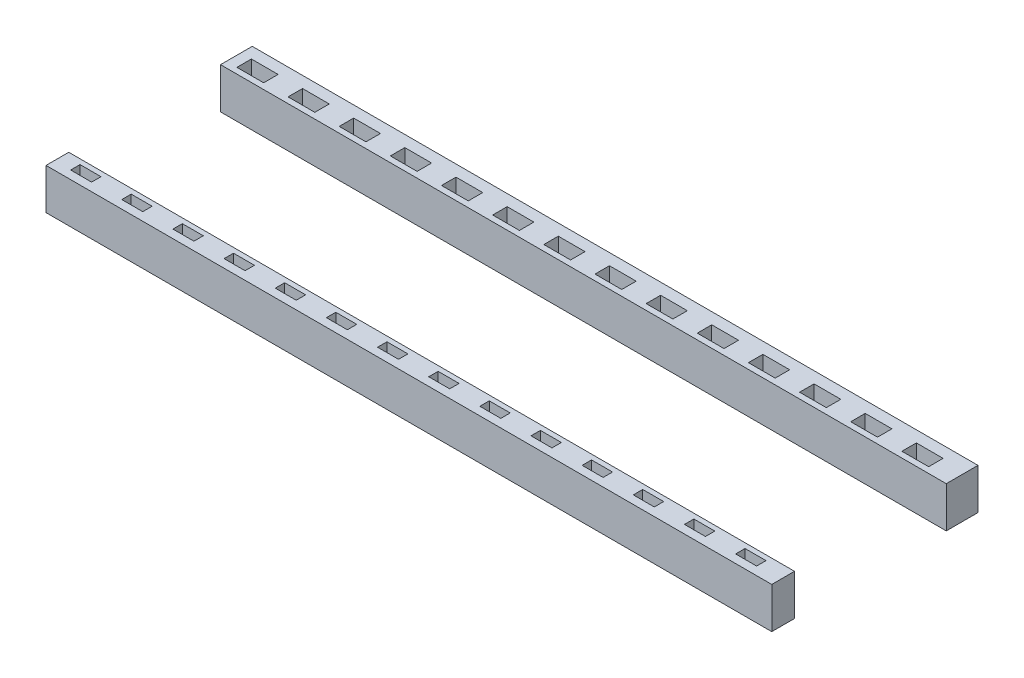
from build123d import *

# Parameters (mm, degrees)
CROQUIS1_W                = 35.470504615
CROQUIS1_H                = 1.551006647
CROQUIS1_W_2              = 1.307281122
CROQUIS1_H_2              = 0.706638445
SALIENTE_EXTRUIR1_DEPTH   = 2
CROQUIS1_H_3              = 1.112257887
CROQUIS1_W_3              = 1.024625744
CROQUIS1_H_4              = 0.459314989
SALIENTE_EXTRUIR1_2_DEPTH = 2
CROQUIS1_3_W              = 1.307281122
CROQUIS1_3_H              = 0.706638445
CROQUIS1_3_W_2            = 1.024625744
CROQUIS1_3_H_2            = 0.459314989
SALIENTE_EXTRUIR2_DEPTH   = 1


with BuildPart() as part:
    # Croquis1 → Saliente-Extruir1 (new body)
    with BuildSketch(Plane(origin=(0, 32.468175746, 0), x_dir=(1, 0, 0), z_dir=(0, 1, 0))):
        with Locations((31.911205321, -56.71845489)):
            Rectangle(CROQUIS1_W, CROQUIS1_H)
        with Locations((15.344131363, -56.853250782)):
            Rectangle(CROQUIS1_W_2, CROQUIS1_H_2, mode=Mode.SUBTRACT)
        with Locations((17.844131363, -56.853250782)):
            Rectangle(CROQUIS1_W_2, CROQUIS1_H_2, mode=Mode.SUBTRACT)
        with Locations((20.344131363, -56.853250782)):
            Rectangle(CROQUIS1_W_2, CROQUIS1_H_2, mode=Mode.SUBTRACT)
        with Locations((22.844131363, -56.853250782)):
            Rectangle(CROQUIS1_W_2, CROQUIS1_H_2, mode=Mode.SUBTRACT)
        with Locations((25.344131363, -56.853250782)):
            Rectangle(CROQUIS1_W_2, CROQUIS1_H_2, mode=Mode.SUBTRACT)
        with Locations((27.844131363, -56.853250782)):
            Rectangle(CROQUIS1_W_2, CROQUIS1_H_2, mode=Mode.SUBTRACT)
        with Locations((30.344131363, -56.853250782)):
            Rectangle(CROQUIS1_W_2, CROQUIS1_H_2, mode=Mode.SUBTRACT)
        with Locations((32.844131363, -56.853250782)):
            Rectangle(CROQUIS1_W_2, CROQUIS1_H_2, mode=Mode.SUBTRACT)
        with Locations((35.344131363, -56.853250782)):
            Rectangle(CROQUIS1_W_2, CROQUIS1_H_2, mode=Mode.SUBTRACT)
        with Locations((37.844131363, -56.853250782)):
            Rectangle(CROQUIS1_W_2, CROQUIS1_H_2, mode=Mode.SUBTRACT)
        with Locations((40.344131363, -56.853250782)):
            Rectangle(CROQUIS1_W_2, CROQUIS1_H_2, mode=Mode.SUBTRACT)
        with Locations((42.844131363, -56.853250782)):
            Rectangle(CROQUIS1_W_2, CROQUIS1_H_2, mode=Mode.SUBTRACT)
        with Locations((45.344131363, -56.853250782)):
            Rectangle(CROQUIS1_W_2, CROQUIS1_H_2, mode=Mode.SUBTRACT)
        with Locations((47.844131363, -56.853250782)):
            Rectangle(CROQUIS1_W_2, CROQUIS1_H_2, mode=Mode.SUBTRACT)
    extrude(amount=SALIENTE_EXTRUIR1_DEPTH)



with BuildPart() as body_2:
    # Croquis1 → Saliente-Extruir1 2 (new body)
    with BuildSketch(Plane(origin=(0, 32.468175746, 0), x_dir=(1, 0, 0), z_dir=(0, 1, 0))):
        with Locations((31.911205321, -65.466420603)):
            Rectangle(CROQUIS1_W, CROQUIS1_H_3)
        with Locations((15.485459052, -65.385910001)):
            Rectangle(CROQUIS1_W_3, CROQUIS1_H_4, mode=Mode.SUBTRACT)
        with Locations((17.985459052, -65.385910001)):
            Rectangle(CROQUIS1_W_3, CROQUIS1_H_4, mode=Mode.SUBTRACT)
        with Locations((20.485459052, -65.385910001)):
            Rectangle(CROQUIS1_W_3, CROQUIS1_H_4, mode=Mode.SUBTRACT)
        with Locations((22.985459052, -65.385910001)):
            Rectangle(CROQUIS1_W_3, CROQUIS1_H_4, mode=Mode.SUBTRACT)
        with Locations((25.485459052, -65.385910001)):
            Rectangle(CROQUIS1_W_3, CROQUIS1_H_4, mode=Mode.SUBTRACT)
        with Locations((27.985459052, -65.385910001)):
            Rectangle(CROQUIS1_W_3, CROQUIS1_H_4, mode=Mode.SUBTRACT)
        with Locations((30.485459052, -65.385910001)):
            Rectangle(CROQUIS1_W_3, CROQUIS1_H_4, mode=Mode.SUBTRACT)
        with Locations((32.985459052, -65.385910001)):
            Rectangle(CROQUIS1_W_3, CROQUIS1_H_4, mode=Mode.SUBTRACT)
        with Locations((35.485459052, -65.385910001)):
            Rectangle(CROQUIS1_W_3, CROQUIS1_H_4, mode=Mode.SUBTRACT)
        with Locations((37.985459052, -65.385910001)):
            Rectangle(CROQUIS1_W_3, CROQUIS1_H_4, mode=Mode.SUBTRACT)
        with Locations((40.485459052, -65.385910001)):
            Rectangle(CROQUIS1_W_3, CROQUIS1_H_4, mode=Mode.SUBTRACT)
        with Locations((42.985459052, -65.385910001)):
            Rectangle(CROQUIS1_W_3, CROQUIS1_H_4, mode=Mode.SUBTRACT)
        with Locations((45.485459052, -65.385910001)):
            Rectangle(CROQUIS1_W_3, CROQUIS1_H_4, mode=Mode.SUBTRACT)
        with Locations((47.985459052, -65.385910001)):
            Rectangle(CROQUIS1_W_3, CROQUIS1_H_4, mode=Mode.SUBTRACT)
    extrude(amount=SALIENTE_EXTRUIR1_2_DEPTH)


with BuildPart() as part_1:
    add(part.part)

    add(body_2.part)  # Saliente-Extruir2 merges body 2
    # Croquis1_3 → Saliente-Extruir2 (add)
    with BuildSketch(Plane(origin=(0, 32.468175746, 0), x_dir=(1, 0, 0), z_dir=(0, 1, 0))):
        with Locations((17.844131363, -56.853250782)):
            Rectangle(CROQUIS1_3_W, CROQUIS1_3_H)
        with Locations((15.344131363, -56.853250782)):
            Rectangle(CROQUIS1_3_W, CROQUIS1_3_H)
        with Locations((15.485459052, -65.385910001)):
            Rectangle(CROQUIS1_3_W_2, CROQUIS1_3_H_2)
        with Locations((17.985459052, -65.385910001)):
            Rectangle(CROQUIS1_3_W_2, CROQUIS1_3_H_2)
        with Locations((20.344131363, -56.853250782)):
            Rectangle(CROQUIS1_3_W, CROQUIS1_3_H)
        with Locations((20.485459052, -65.385910001)):
            Rectangle(CROQUIS1_3_W_2, CROQUIS1_3_H_2)
        with Locations((22.844131363, -56.853250782)):
            Rectangle(CROQUIS1_3_W, CROQUIS1_3_H)
        with Locations((22.985459052, -65.385910001)):
            Rectangle(CROQUIS1_3_W_2, CROQUIS1_3_H_2)
        with Locations((25.344131363, -56.853250782)):
            Rectangle(CROQUIS1_3_W, CROQUIS1_3_H)
        with Locations((25.485459052, -65.385910001)):
            Rectangle(CROQUIS1_3_W_2, CROQUIS1_3_H_2)
        with Locations((27.844131363, -56.853250782)):
            Rectangle(CROQUIS1_3_W, CROQUIS1_3_H)
        with Locations((27.985459052, -65.385910001)):
            Rectangle(CROQUIS1_3_W_2, CROQUIS1_3_H_2)
        with Locations((30.344131363, -56.853250782)):
            Rectangle(CROQUIS1_3_W, CROQUIS1_3_H)
        with Locations((30.485459052, -65.385910001)):
            Rectangle(CROQUIS1_3_W_2, CROQUIS1_3_H_2)
        with Locations((32.844131363, -56.853250782)):
            Rectangle(CROQUIS1_3_W, CROQUIS1_3_H)
        with Locations((32.985459052, -65.385910001)):
            Rectangle(CROQUIS1_3_W_2, CROQUIS1_3_H_2)
        with Locations((35.344131363, -56.853250782)):
            Rectangle(CROQUIS1_3_W, CROQUIS1_3_H)
        with Locations((35.485459052, -65.385910001)):
            Rectangle(CROQUIS1_3_W_2, CROQUIS1_3_H_2)
        with Locations((37.844131363, -56.853250782)):
            Rectangle(CROQUIS1_3_W, CROQUIS1_3_H)
        with Locations((37.985459052, -65.385910001)):
            Rectangle(CROQUIS1_3_W_2, CROQUIS1_3_H_2)
        with Locations((40.344131363, -56.853250782)):
            Rectangle(CROQUIS1_3_W, CROQUIS1_3_H)
        with Locations((40.485459052, -65.385910001)):
            Rectangle(CROQUIS1_3_W_2, CROQUIS1_3_H_2)
        with Locations((42.844131363, -56.853250782)):
            Rectangle(CROQUIS1_3_W, CROQUIS1_3_H)
        with Locations((42.985459052, -65.385910001)):
            Rectangle(CROQUIS1_3_W_2, CROQUIS1_3_H_2)
        with Locations((45.344131363, -56.853250782)):
            Rectangle(CROQUIS1_3_W, CROQUIS1_3_H)
        with Locations((45.485459052, -65.385910001)):
            Rectangle(CROQUIS1_3_W_2, CROQUIS1_3_H_2)
        with Locations((47.844131363, -56.853250782)):
            Rectangle(CROQUIS1_3_W, CROQUIS1_3_H)
        with Locations((47.985459052, -65.385910001)):
            Rectangle(CROQUIS1_3_W_2, CROQUIS1_3_H_2)
    extrude(amount=SALIENTE_EXTRUIR2_DEPTH)


solid = part_1.part
